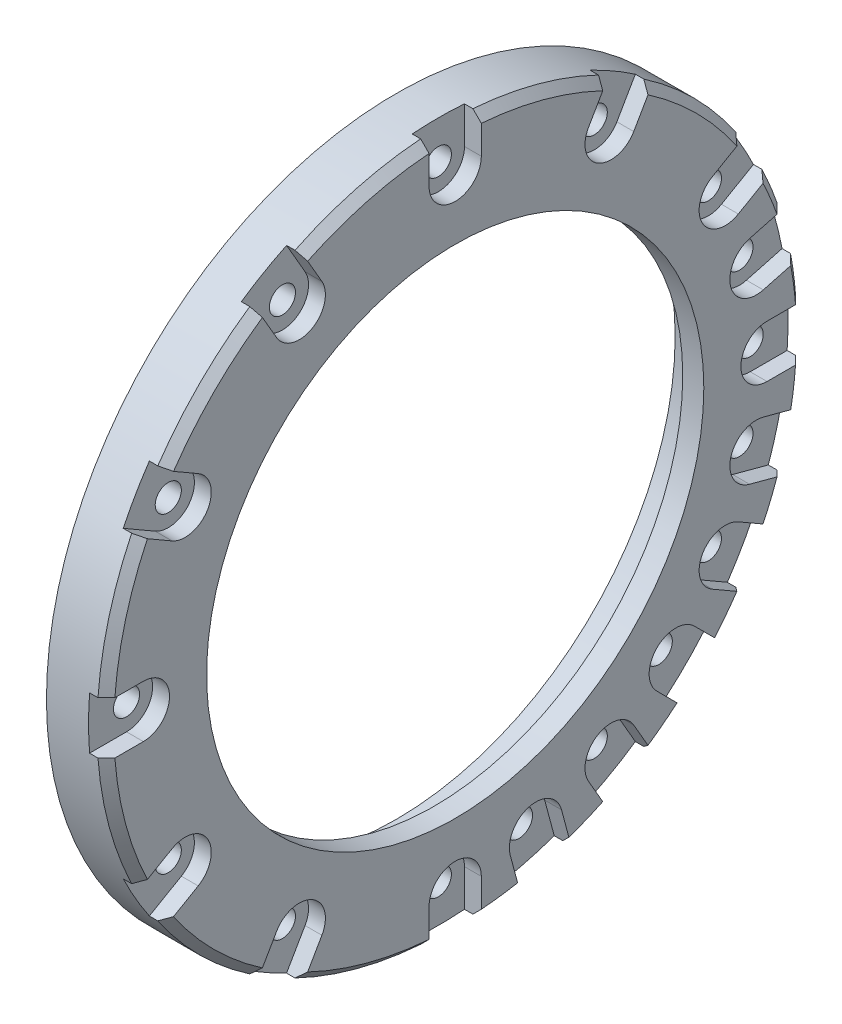
from build123d import *

# Parameters (mm, degrees)
SKETCH_1_R                = 41.5
SKETCH_1_R_2              = 33.1
EXTRUDE_1_DEPTH           = 7
SKETCH_2_R                = 1.55
CUT_EXTRUDE_1_DEPTH       = 8
PATTERN_CIRCULAR_1_COUNT  = 12
SKETCH_3_R                = 33.1
SKETCH_3_R_2              = 29.5
EXTRUDE_2_DEPTH           = 2.5
CHAMFER_1_SIZE            = 1
SKETCH_4_R                = 1.55
CUT_EXTRUDE_8_DEPTH       = 2
PATTERN_CIRCULAR_7_COUNT  = 12
SKETCH_7_R                = 1.6
CUT_EXTRUDE_10_DEPTH      = 10
PATTERN_CIRCULAR_9_COUNT  = 4
PATTERN_CIRCULAR_9_ANGLE  = 90
SKETCH_6_R                = 3
CUT_EXTRUDE_9_DEPTH       = 3.5
PATTERN_CIRCULAR_8_COUNT  = 4
PATTERN_CIRCULAR_8_ANGLE  = 90
SKETCH_8_R                = 1.6
CUT_EXTRUDE_11_DEPTH      = 2
PATTERN_CIRCULAR_10_COUNT = 4
PATTERN_CIRCULAR_10_ANGLE = 90


with BuildPart() as part:
    # 草图1 → 凸台-拉伸1 (new body)
    with BuildSketch(Plane(origin=(0, 0, 0), x_dir=(0, 0, -1), z_dir=(1, 0, 0))):
        Circle(SKETCH_1_R)
        Circle(SKETCH_1_R_2, mode=Mode.SUBTRACT)
    extrude(amount=EXTRUDE_1_DEPTH)

    # 草图2 → 切除-拉伸1 (cut)
    with BuildSketch(Plane.ZY):
        with Locations((0, 37)):
            Circle(SKETCH_2_R)
    cut_extrude_1 = extrude(amount=-CUT_EXTRUDE_1_DEPTH, mode=Mode.SUBTRACT)

    # 阵列(圆周)1: 切除-拉伸1 ×12 about axis
    pattern_circular_1_axis = Axis((0, 0, 0), (1, 0, 0))
    for i in range(1, PATTERN_CIRCULAR_1_COUNT):
        add(cut_extrude_1.rotate(pattern_circular_1_axis, i * 360 / PATTERN_CIRCULAR_1_COUNT), mode=Mode.SUBTRACT)

    # 草图3 → 凸台-拉伸2 (add)
    with BuildSketch(Plane(origin=(7, 0, 0), x_dir=(0, 0, -1), z_dir=(1, 0, 0))):
        Circle(SKETCH_3_R)
        Circle(SKETCH_3_R_2, mode=Mode.SUBTRACT)
    extrude(amount=-EXTRUDE_2_DEPTH)

    # 倒角1
    chamfer_1_edges = [part.edges().sort_by_distance(p)[0] for p in [
        (7, 0, 41.5),
    ]]
    chamfer(chamfer_1_edges, length=CHAMFER_1_SIZE)

    # 草图4 → 切除-拉伸8 (cut)
    with BuildSketch(Plane(origin=(7, 0, 0), x_dir=(0, 0, -1), z_dir=(1, 0, 0))):
        with BuildLine():
            Line((40.381183737, 3.1), (37, 3.1))
            ThreePointArc((37, 3.1), (33.9, 0), (37, -3.1))
            Line((37, -3.1), (40.381183737, -3.1))
            ThreePointArc((40.381183737, -3.1), (40.470285033, -1.551138074), (40.5, 0))
            ThreePointArc((40.5, 0), (40.470285033, 1.551138074), (40.381183737, 3.1))
        make_face()
        with Locations((37, 0)):
            Circle(SKETCH_4_R, mode=Mode.SUBTRACT)
        with BuildLine():
            Line((41.5, 3.1), (40.381183737, 3.1))
            ThreePointArc((40.381183737, 3.1), (40.470285033, 1.551138074), (40.5, 0))
            ThreePointArc((40.5, 0), (40.470285033, -1.551138074), (40.381183737, -3.1))
            Line((40.381183737, -3.1), (41.5, -3.1))
            ThreePointArc((41.5, -3.1), (44.6, 0), (41.5, 3.1))
        make_face()
    cut_extrude_8 = extrude(amount=-CUT_EXTRUDE_8_DEPTH, mode=Mode.SUBTRACT)

    # 阵列(圆周)7: 切除-拉伸8 ×12 about axis
    pattern_circular_7_axis = Axis((0, 0, 0), (1, 0, 0))
    for i in range(1, PATTERN_CIRCULAR_7_COUNT):
        add(cut_extrude_8.rotate(pattern_circular_7_axis, i * 360 / PATTERN_CIRCULAR_7_COUNT), mode=Mode.SUBTRACT)

    # 草图7 → 切除-拉伸10 (cut)
    with BuildSketch(Plane.ZY):
        with Locations((-9.576304669, -35.739255573)):
            Circle(SKETCH_7_R)
    cut_extrude_10 = extrude(amount=-CUT_EXTRUDE_10_DEPTH, mode=Mode.SUBTRACT)

    # 阵列(圆周)9: 切除-拉伸10 ×4 about axis
    pattern_circular_9_axis = Axis((0, 0, 0), (1, 0, 0))
    for i in range(1, PATTERN_CIRCULAR_9_COUNT):
        add(cut_extrude_10.rotate(pattern_circular_9_axis, i * PATTERN_CIRCULAR_9_ANGLE / (PATTERN_CIRCULAR_9_COUNT - 1)), mode=Mode.SUBTRACT)

    # 草图6 → 切除-拉伸9 (cut)
    with BuildSketch(Plane.ZY):
        with Locations((-9.576304669, -35.739255573)):
            Circle(SKETCH_6_R)
    cut_extrude_9 = extrude(amount=-CUT_EXTRUDE_9_DEPTH, mode=Mode.SUBTRACT)

    # 阵列(圆周)8: 切除-拉伸9 ×4 about axis
    pattern_circular_8_axis = Axis((0, 0, 0), (1, 0, 0))
    for i in range(1, PATTERN_CIRCULAR_8_COUNT):
        add(cut_extrude_9.rotate(pattern_circular_8_axis, i * PATTERN_CIRCULAR_8_ANGLE / (PATTERN_CIRCULAR_8_COUNT - 1)), mode=Mode.SUBTRACT)

    # 草图8 → 切除-拉伸11 (cut)
    with BuildSketch(Plane(origin=(7, 0, 0), x_dir=(0, 0, -1), z_dir=(1, 0, 0))):
        with BuildLine():
            ThreePointArc((38.889255573, 9.576304669), (37.656854074, 12.075367691), (34.923975581, 12.618971022))
            ThreePointArc((34.923975581, 12.618971022), (32.69658922, 8.761024677), (36.554535565, 6.533638316))
            ThreePointArc((36.554535565, 6.533638316), (38.238318595, 7.658706167), (38.889255573, 9.576304669))
        make_face()
        with Locations((35.739255573, 9.576304669)):
            Circle(SKETCH_8_R, mode=Mode.SUBTRACT)
        with BuildLine():
            Line((40.719530538, 14.171885292), (34.923975581, 12.618971022))
            ThreePointArc((34.923975581, 12.618971022), (37.656854074, 12.075367691), (38.889255573, 9.576304669))
            ThreePointArc((38.889255573, 9.576304669), (38.238318595, 7.658706167), (36.554535565, 6.533638316))
            Line((36.554535565, 6.533638316), (42.350090523, 8.086552587))
            Line((42.350090523, 8.086552587), (40.719530538, 14.171885292))
        make_face()
    cut_extrude_11 = extrude(amount=-CUT_EXTRUDE_11_DEPTH, mode=Mode.SUBTRACT)

    # 阵列(圆周)10: 切除-拉伸11 ×4 about axis
    pattern_circular_10_axis = Axis((0, 0, 0), (-1, 0, 0))
    for i in range(1, PATTERN_CIRCULAR_10_COUNT):
        add(cut_extrude_11.rotate(pattern_circular_10_axis, i * PATTERN_CIRCULAR_10_ANGLE / (PATTERN_CIRCULAR_10_COUNT - 1)), mode=Mode.SUBTRACT)


solid = part.part
